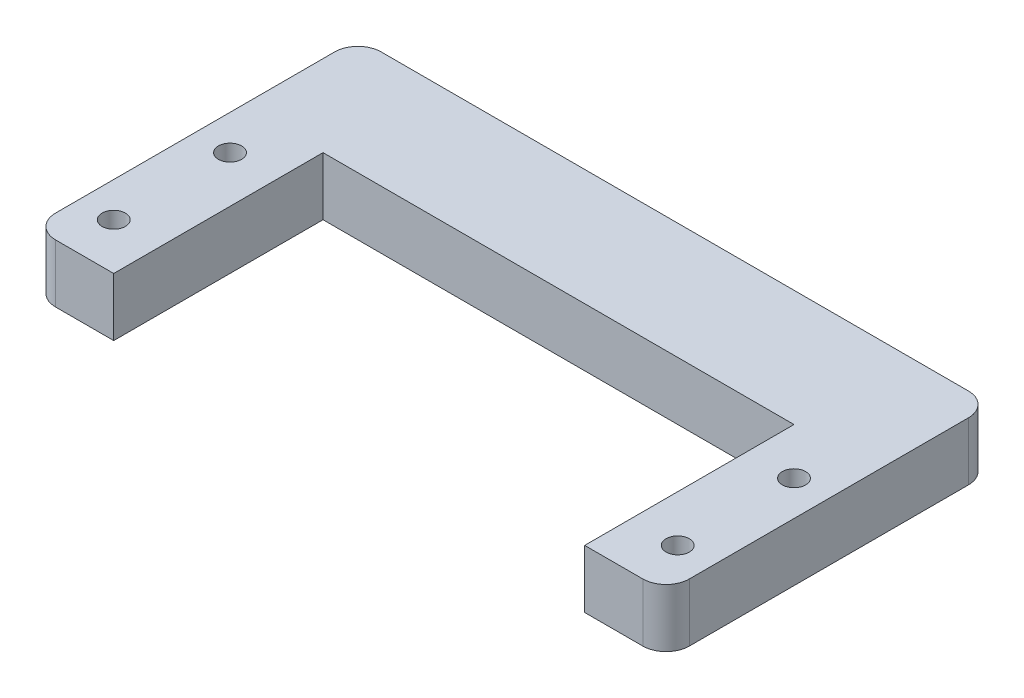
from build123d import *

# Parameters (mm, degrees)
SKETCH1_R           = 1
BOSS_EXTRUDE2_DEPTH = 5
FILLET1_R           = 2


with BuildPart() as part:
    # Sketch1 → Boss-Extrude2 (new body)
    with BuildSketch(Plane(origin=(0, 0, 0), x_dir=(1, 0, 0), z_dir=(0, 1, 0))):
        with BuildLine():
            ThreePointArc((-25.25, -9), (-26.664213562, -8.414213562), (-27.25, -7))
            Line((-27.25, -7), (-27.25, 9))
            Line((-27.25, 9), (-20.25, 9))
            Line((-20.25, 9), (-20.25, -9))
            Line((-20.25, -9), (-25.25, -9))
        make_face()
        with Locations((-24.25, -5)):
            Circle(SKETCH1_R, mode=Mode.SUBTRACT)
        with Locations((-24.25, 5)):
            Circle(SKETCH1_R, mode=Mode.SUBTRACT)
        Polygon((-27.25, 9), (-20.25, 9), (20.25, 9), (27.25, 9), (27.25, 19), (-27.25, 19), align=None)
        with BuildLine():
            ThreePointArc((27.25, -7), (26.664213562, -8.414213562), (25.25, -9))
            Line((25.25, -9), (20.25, -9))
            Line((20.25, -9), (20.25, 9))
            Line((20.25, 9), (27.25, 9))
            Line((27.25, 9), (27.25, -7))
        make_face()
        with Locations((24.25, 5)):
            Circle(SKETCH1_R, mode=Mode.SUBTRACT)
        with Locations((24.25, -5)):
            Circle(SKETCH1_R, mode=Mode.SUBTRACT)
    extrude(amount=BOSS_EXTRUDE2_DEPTH)

    # Fillet1
    fillet1_edges = [part.edges().sort_by_distance(p)[0] for p in [
        (-27.25, 2.5, -19),
        (27.25, 2.5, -19),
    ]]
    fillet(fillet1_edges, radius=FILLET1_R)


solid = part.part
